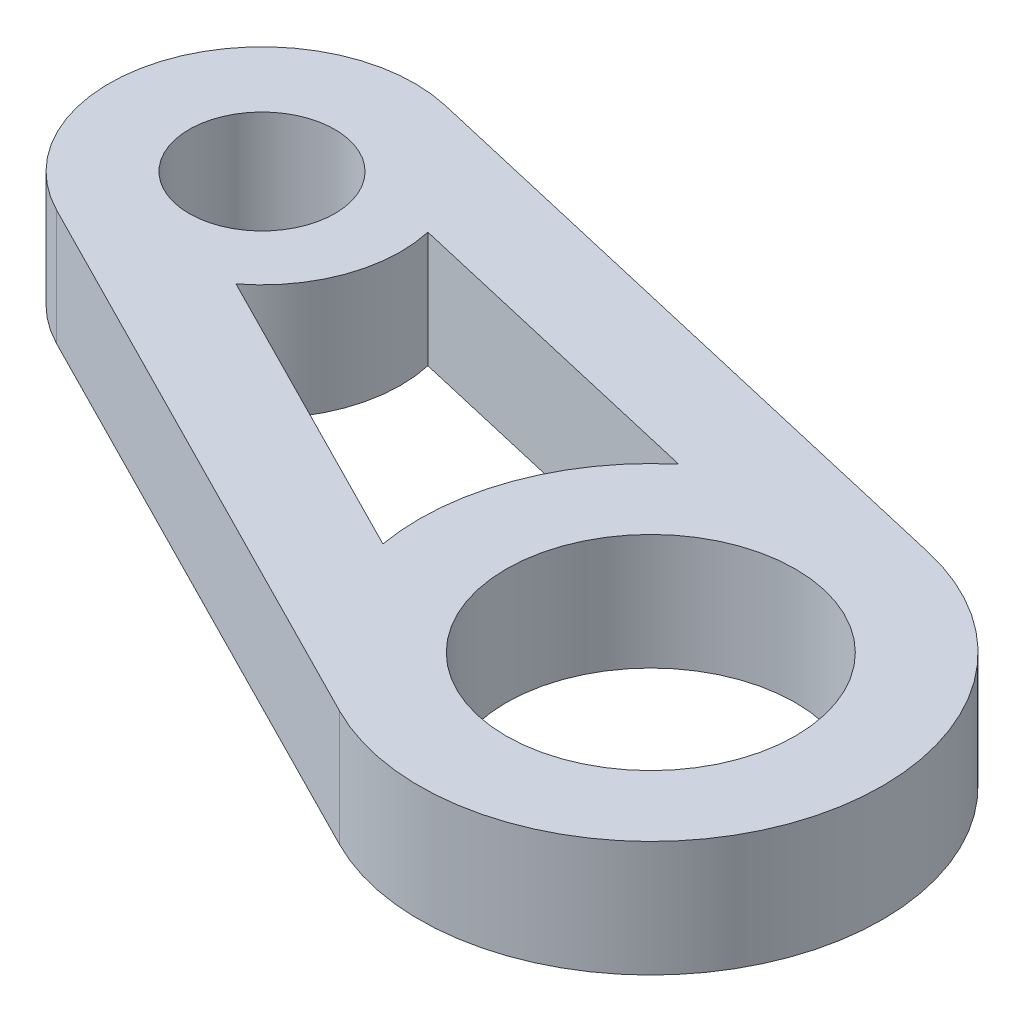
from build123d import *

# Parameters (mm, degrees)
SKETCH1_R           = 2
SKETCH1_R_2         = 3.96875
BOSS_EXTRUDE1_DEPTH = 3.175


with BuildPart() as part:
    # Sketch1 → Boss-Extrude1 (new body)
    with BuildSketch(Plane(origin=(0, 0, 0), x_dir=(1, 0, 0), z_dir=(0, 1, 0))):
        with BuildLine():
            Line((18.195821705, 0.090468023), (0.945002326, 4.083068895))
            ThreePointArc((0.945002326, 4.083068895), (-3.938674238, 1.432245177), (-1.898429333, -3.736368165))
            Line((-1.898429333, -3.736368165), (13.88759192, -11.757163887))
            ThreePointArc((13.88759192, -11.757163887), (22.731688239, -8.266068451), (18.195821705, 0.090468023))
        make_face()
        Circle(SKETCH1_R, mode=Mode.SUBTRACT)
        with Locations((16.764, -6.096)):
            Circle(SKETCH1_R_2, mode=Mode.SUBTRACT)
        with BuildLine():
            Line((10.509224042, -7.191571868), (2.313352981, -3.027292187))
            ThreePointArc((2.313352981, -3.027292187), (3.580612943, -1.30204107), (3.717545806, 0.834238083))
            Line((3.717545806, 0.834238083), (12.673918605, -1.238661822))
            ThreePointArc((12.673918605, -1.238661822), (10.796311761, -3.925931549), (10.509224042, -7.191571868))
        make_face(mode=Mode.SUBTRACT)
    extrude(amount=BOSS_EXTRUDE1_DEPTH)


solid = part.part
